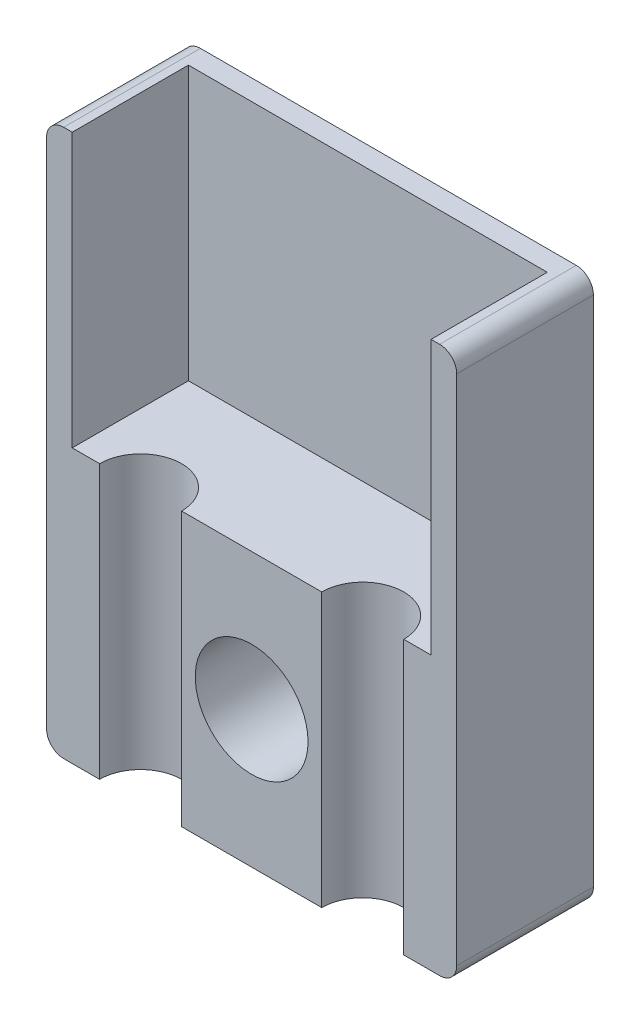
from build123d import *

# Parameters (mm, degrees)
SKETCH1_R           = 1.65
BOSS_EXTRUDE1_DEPTH = 4
CUT_EXTRUDE1_DEPTH  = 16
SKETCH3_W           = 10.5
SKETCH3_H           = 3.4
CUT_EXTRUDE2_DEPTH  = 8


with BuildPart() as part:
    # Sketch1 → Boss-Extrude1 (new body)
    with BuildSketch(Plane.XY):
        with BuildLine():
            Line((0.5, 0), (11.5, 0))
            ThreePointArc((11.5, 0), (11.853553391, 0.146446609), (12, 0.5))
            Line((12, 0.5), (12, 15.5))
            ThreePointArc((12, 15.5), (11.853553391, 15.853553391), (11.5, 16))
            Line((11.5, 16), (0.5, 16))
            ThreePointArc((0.5, 16), (0.146446609, 15.853553391), (0, 15.5))
            Line((0, 15.5), (0, 0.5))
            ThreePointArc((0, 0.5), (0.146446609, 0.146446609), (0.5, 0))
        make_face()
        with Locations((6, 4)):
            Circle(SKETCH1_R, mode=Mode.SUBTRACT)
    extrude(amount=BOSS_EXTRUDE1_DEPTH)

    # Sketch2 → Cut-Extrude1 (cut)
    with BuildSketch(Plane.XZ):
        with BuildLine():
            Line((1.55, 4), (3.95, 4))
            ThreePointArc((3.95, 4), (2.75, 2.8), (1.55, 4))
        make_face()
        with BuildLine():
            Line((8.05, 4), (10.45, 4))
            ThreePointArc((10.45, 4), (9.25, 2.8), (8.05, 4))
        make_face()
    extrude(amount=-CUT_EXTRUDE1_DEPTH, mode=Mode.SUBTRACT)

    # Sketch3 → Cut-Extrude2 (cut)
    with BuildSketch(Plane(origin=(0, 16, 0), x_dir=(1, 0, 0), z_dir=(0, 1, 0))):
        with Locations((6, -2.3)):
            Rectangle(SKETCH3_W, SKETCH3_H)
    extrude(amount=-CUT_EXTRUDE2_DEPTH, mode=Mode.SUBTRACT)


solid = part.part
